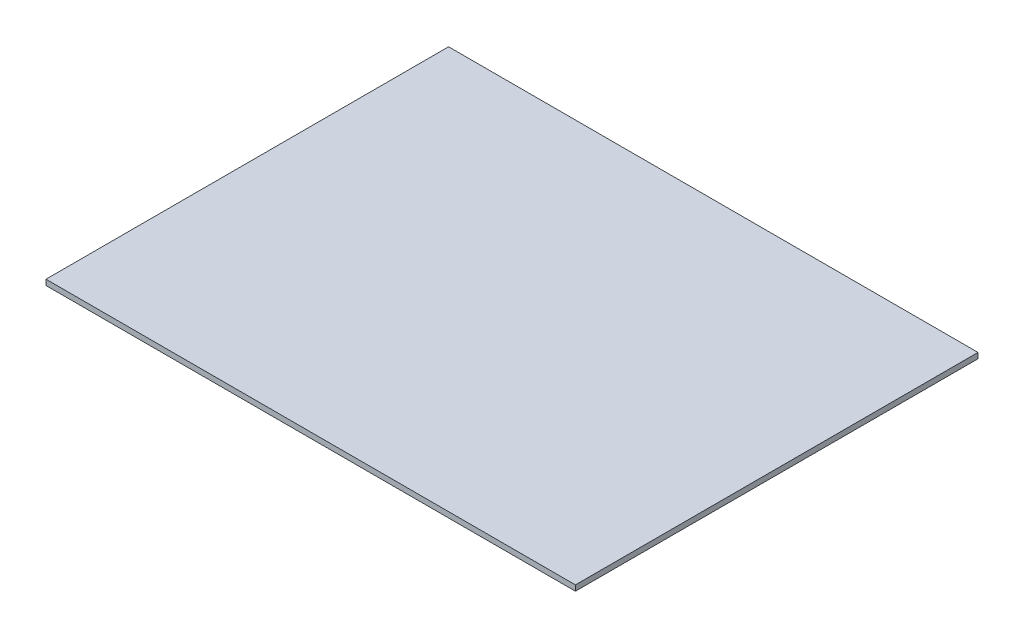
from build123d import *

# Parameters (mm, degrees)
SKETCH1_W           = 243.84
SKETCH1_H           = 185.42
BOSS_EXTRUDE1_DEPTH = 2.54


with BuildPart() as part:
    # Sketch1 → Boss-Extrude1 (new body)
    with BuildSketch(Plane(origin=(0, 0, 0), x_dir=(1, 0, 0), z_dir=(0, 1, 0))):
        with Locations((-121.92, 6.295123457)):
            Rectangle(SKETCH1_W, SKETCH1_H)
    extrude(amount=BOSS_EXTRUDE1_DEPTH)


solid = part.part
